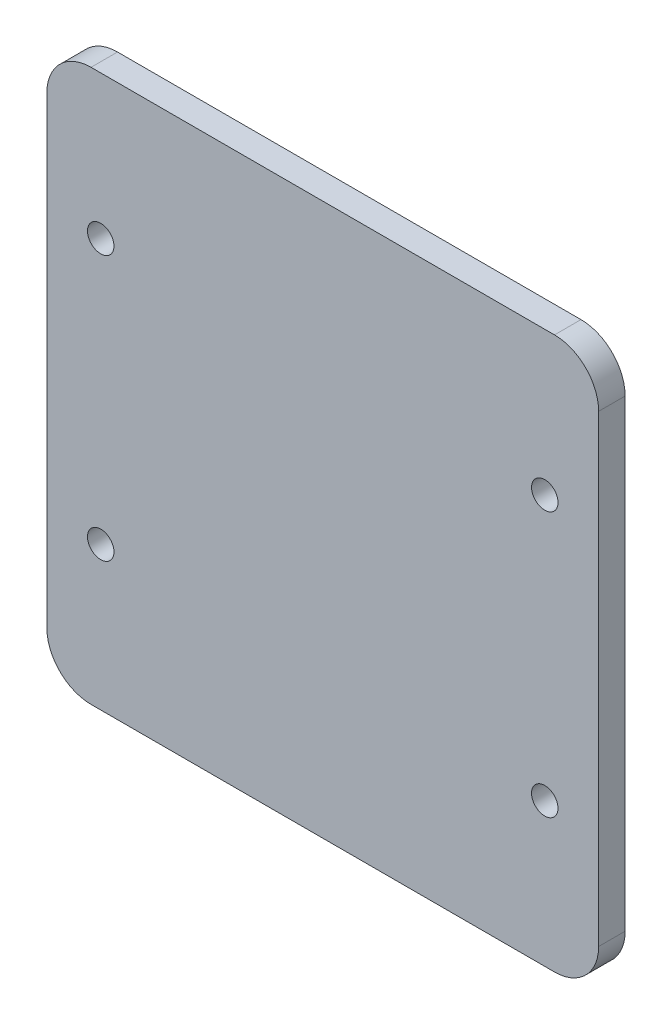
from build123d import *

# Parameters (mm, degrees)
SKETCH1_W           = 125
SKETCH1_H           = 125
BOSS_EXTRUDE1_DEPTH = 6
FILLET1_R           = 10
SKETCH9_R           = 3
CUT_EXTRUDE1_DEPTH  = 10


with BuildPart() as part:
    # Sketch1 → Boss-Extrude1 (new body)
    with BuildSketch(Plane.XY):
        Rectangle(SKETCH1_W, SKETCH1_H)
    extrude(amount=BOSS_EXTRUDE1_DEPTH)

    # Fillet1
    fillet1_edges = [part.edges().sort_by_distance(p)[0] for p in [
        (-62.5, 62.5, 3),
        (62.5, 62.5, 3),
        (62.5, -62.5, 3),
        (-62.5, -62.5, 3),
    ]]
    fillet(fillet1_edges, radius=FILLET1_R)

    # Sketch9 → Cut-Extrude1 (cut)
    with BuildSketch(Plane.XY.offset(6)):
        with Locations((50.3, 30)):
            Circle(SKETCH9_R)
        with Locations((50.3, -30)):
            Circle(SKETCH9_R)
        with Locations((-50.3, 30)):
            Circle(SKETCH9_R)
        with Locations((-50.3, -30)):
            Circle(SKETCH9_R)
    extrude(amount=-CUT_EXTRUDE1_DEPTH, mode=Mode.SUBTRACT)


solid = part.part
